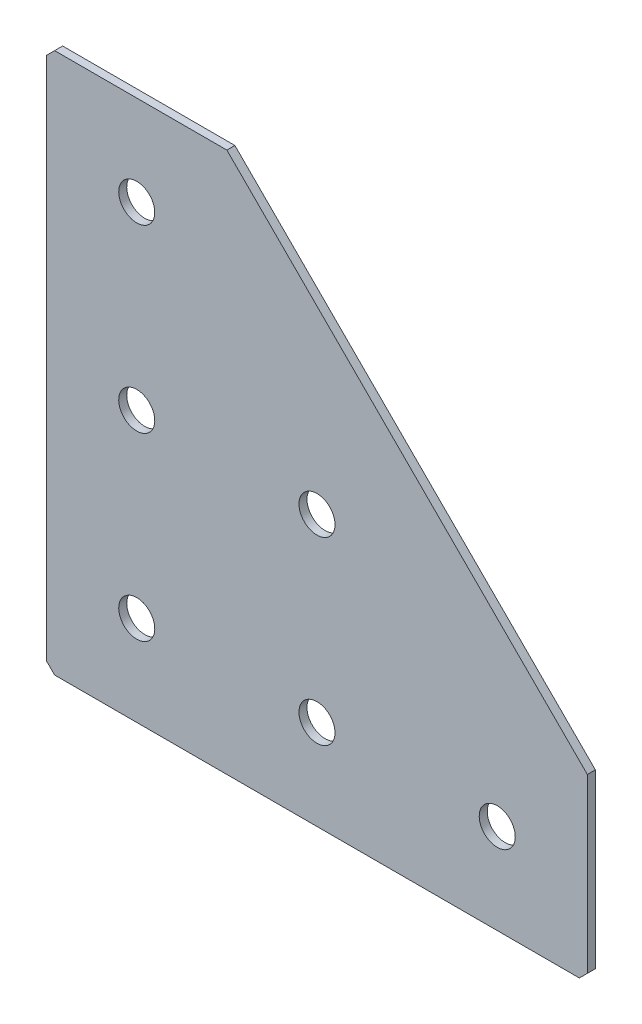
from build123d import *

# Parameters (mm, degrees)
EXTRUDE_1_DEPTH   = 2
HOLE_WIZARD_M81_D = 9
CHAMFER_1_SIZE    = 2


with BuildPart() as part:
    # Эскиз1 → Бобышка-Вытянуть1 (new body)
    with BuildSketch(Plane(origin=(0, 0, 0), x_dir=(1, 0, 0), z_dir=(0, 0, -1))):
        Polygon((0, 0), (0, 135), (135, 135), (135, 90), (45, 0), align=None)
    extrude(amount=EXTRUDE_1_DEPTH)

    # Отверстие с зазором M81 (through all)
    with Locations(Plane(origin=(0, 0, -2), x_dir=(1, 0, 0), z_dir=(0, 0, -1))):
        with Locations((67.5, 112.5), (22.5, 112.5), (22.5, 67.5), (22.5, 22.5), (112.5, 112.5), (67.5, 67.5)):
            Hole(HOLE_WIZARD_M81_D / 2)

    # Фаска1
    chamfer_1_edges = [part.edges().sort_by_distance(p)[0] for p in [
        (0, 0, -1),
        (0, -135, -1),
        (135, -135, -1),
    ]]
    chamfer(chamfer_1_edges, length=CHAMFER_1_SIZE)


solid = part.part
